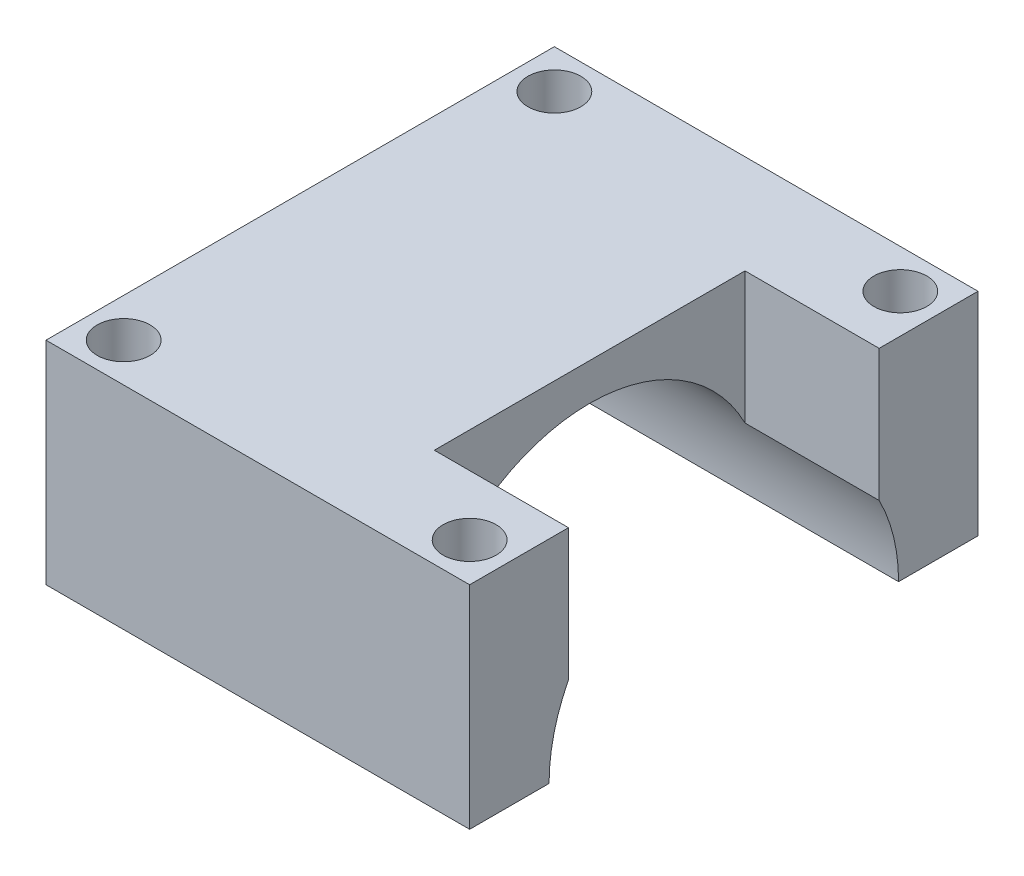
from build123d import *

# Parameters (mm, degrees)
SKETCH1_W           = 30
SKETCH1_H           = 36
BOSS_EXTRUDE1_DEPTH = 30
SKETCH3_R           = 12.375
CUT_EXTRUDE1_DEPTH  = 40
SKETCH5_R           = 1.875
CUT_EXTRUDE2_DEPTH  = 40
CUT_EXTRUDE3_START  = 15
SKETCH7_W           = 36
SKETCH7_H           = 15
CUT_EXTRUDE3_DEPTH  = 31
SKETCH8_W           = 9.5
SKETCH8_H           = 22
CUT_EXTRUDE4_DEPTH  = 10


with BuildPart() as part:
    # Sketch1 → Boss-Extrude1 (new body)
    with BuildSketch(Plane(origin=(0, 0, 0), x_dir=(1, 0, 0), z_dir=(0, 1, 0))):
        Rectangle(SKETCH1_W, SKETCH1_H)
    extrude(amount=BOSS_EXTRUDE1_DEPTH)

    # Sketch3 → Cut-Extrude1 (cut)
    with BuildSketch(Plane(origin=(15, 0, 0), x_dir=(0, 0, -1), z_dir=(1, 0, 0))):
        with Locations((0, 15)):
            Circle(SKETCH3_R)
    extrude(amount=-CUT_EXTRUDE1_DEPTH, mode=Mode.SUBTRACT)

    # Sketch5 → Cut-Extrude2 (cut)
    with BuildSketch(Plane(origin=(0, 30, 0), x_dir=(1, 0, 0), z_dir=(0, 1, 0))):
        with Locations((-12.25, 15.25)):
            Circle(SKETCH5_R)
        with Locations((-12.25, -15.25)):
            Circle(SKETCH5_R)
        with Locations((12.25, -15.25)):
            Circle(SKETCH5_R)
        with Locations((12.25, 15.25)):
            Circle(SKETCH5_R)
    extrude(amount=-CUT_EXTRUDE2_DEPTH, mode=Mode.SUBTRACT)

    # Sketch7 → Cut-Extrude3 (cut, through all)
    with BuildSketch(Plane(origin=(0, 0, 0), x_dir=(0, 0, -1), z_dir=(1, 0, 0)).offset(CUT_EXTRUDE3_START)):
        with Locations((0, 7.5)):
            Rectangle(SKETCH7_W, SKETCH7_H)
    extrude(amount=-CUT_EXTRUDE3_DEPTH, mode=Mode.SUBTRACT)

    # Sketch8 → Cut-Extrude4 (cut)
    with BuildSketch(Plane(origin=(0, 30, 0), x_dir=(1, 0, 0), z_dir=(0, 1, 0))):
        with Locations((10.25, 0)):
            Rectangle(SKETCH8_W, SKETCH8_H)
    extrude(amount=-CUT_EXTRUDE4_DEPTH, mode=Mode.SUBTRACT)


solid = part.part
